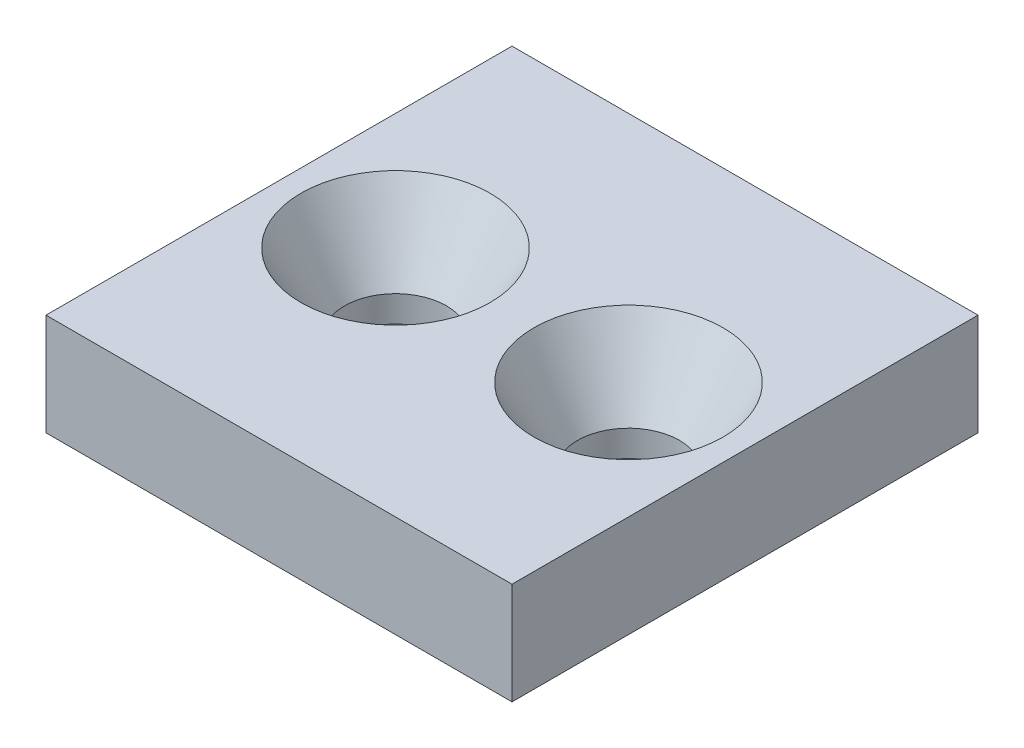
from build123d import *

# Parameters (mm, degrees)
SKETCH2_W           = 32
SKETCH2_H           = 32
SKETCH2_R           = 3.5
BOSS_EXTRUDE1_DEPTH = 7
CHAMFER2_SIZE       = 3
CHAMFER2_SIZE2      = 5.196152423
CHAMFER3_SIZE       = 3
CHAMFER3_SIZE2      = 5.196152423


with BuildPart() as part:
    # Sketch2 → Boss-Extrude1 (new body)
    with BuildSketch(Plane(origin=(0, 0, 0), x_dir=(1, 0, 0), z_dir=(0, 1, 0))):
        with Locations((16, 16)):
            Rectangle(SKETCH2_W, SKETCH2_H)
        with Locations((8, 16)):
            Circle(SKETCH2_R, mode=Mode.SUBTRACT)
        with Locations((24, 16)):
            Circle(SKETCH2_R, mode=Mode.SUBTRACT)
    extrude(amount=BOSS_EXTRUDE1_DEPTH)

    # Chamfer2
    chamfer2_edges = [part.edges().sort_by_distance(p)[0] for p in [
        (20.5, 7, -16),
    ]]
    chamfer2_side = [part.faces().sort_by_distance(p)[0] for p in [
        (16, 7, -16),
    ]]
    chamfer(chamfer2_edges, length=CHAMFER2_SIZE, length2=CHAMFER2_SIZE2, reference=chamfer2_side[0])

    # Chamfer3
    chamfer3_edges = [part.edges().sort_by_distance(p)[0] for p in [
        (4.5, 7, -16),
    ]]
    chamfer3_side = [part.faces().sort_by_distance(p)[0] for p in [
        (15.115857071, 7, -16),
    ]]
    chamfer(chamfer3_edges, length=CHAMFER3_SIZE, length2=CHAMFER3_SIZE2, reference=chamfer3_side[0])


solid = part.part
